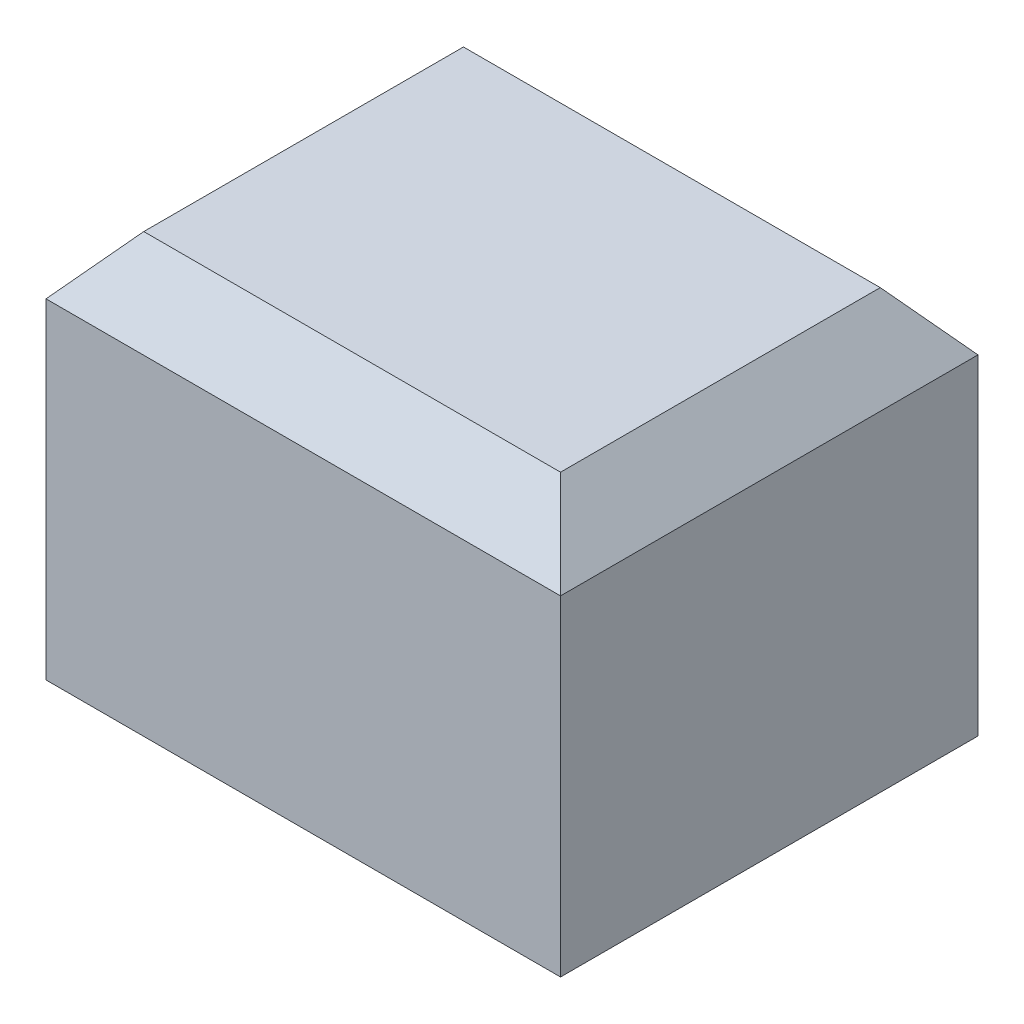
from build123d import *

# Parameters (mm, degrees)
SKETCH1_W                = 5.3
SKETCH1_H                = 4.3
SKETCH1_W_2              = 3.1
SKETCH1_H_2              = 2.1
BODY_EXTRUDE_DEPTH       = 2.8
SKETCH2_W                = 5.3
SKETCH2_H                = 4.3
CAP_EXTRUDE_DEPTH        = 1.2
BED_CHAMFER_SIZE         = 0.6
BED_CHAMFER_SIZE2        = 0.503459779
BED_CHAMFER_PART_2_SIZE  = 0.6
BED_CHAMFER_PART_2_SIZE2 = 0.503459779
BED_CHAMFER_PART_3_SIZE  = 0.6
BED_CHAMFER_PART_3_SIZE2 = 0.503459779
BED_CHAMFER_PART_4_SIZE  = 0.6
BED_CHAMFER_PART_4_SIZE2 = 0.503459779


with BuildPart() as part:
    # Sketch1 → Body Extrude (new body)
    with BuildSketch(Plane(origin=(0, 0, 0), x_dir=(1, 0, 0), z_dir=(0, 1, 0))):
        Rectangle(SKETCH1_W, SKETCH1_H)
        Rectangle(SKETCH1_W_2, SKETCH1_H_2, mode=Mode.SUBTRACT)
    extrude(amount=BODY_EXTRUDE_DEPTH)

    # Sketch2 → Cap Extrude (add)
    with BuildSketch(Plane(origin=(0, 2.8, 0), x_dir=(1, 0, 0), z_dir=(0, 1, 0))):
        Rectangle(SKETCH2_W, SKETCH2_H)
    extrude(amount=CAP_EXTRUDE_DEPTH)

    # Bed Chamfer
    bed_chamfer_edges = [part.edges().sort_by_distance(p)[0] for p in [
        (-2.65, 4, 0),
    ]]
    bed_chamfer_side = [part.faces().sort_by_distance(p)[0] for p in [
        (-2.65, 2, 0),
    ]]
    chamfer(bed_chamfer_edges, length=BED_CHAMFER_SIZE, length2=BED_CHAMFER_SIZE2, reference=bed_chamfer_side[0])

    # Bed Chamfer part 2
    bed_chamfer_part_2_edges = [part.edges().sort_by_distance(p)[0] for p in [
        (0, 4, 2.15),
    ]]
    bed_chamfer_part_2_side = [part.faces().sort_by_distance(p)[0] for p in [
        (0, 2, 2.15),
    ]]
    chamfer(bed_chamfer_part_2_edges, length=BED_CHAMFER_PART_2_SIZE, length2=BED_CHAMFER_PART_2_SIZE2, reference=bed_chamfer_part_2_side[0])

    # Bed Chamfer part 3
    bed_chamfer_part_3_edges = [part.edges().sort_by_distance(p)[0] for p in [
        (2.65, 4, 0),
    ]]
    bed_chamfer_part_3_side = [part.faces().sort_by_distance(p)[0] for p in [
        (2.65, 2, 0),
    ]]
    chamfer(bed_chamfer_part_3_edges, length=BED_CHAMFER_PART_3_SIZE, length2=BED_CHAMFER_PART_3_SIZE2, reference=bed_chamfer_part_3_side[0])

    # Bed Chamfer part 4
    bed_chamfer_part_4_edges = [part.edges().sort_by_distance(p)[0] for p in [
        (0, 4, -2.15),
    ]]
    bed_chamfer_part_4_side = [part.faces().sort_by_distance(p)[0] for p in [
        (0, 2, -2.15),
    ]]
    chamfer(bed_chamfer_part_4_edges, length=BED_CHAMFER_PART_4_SIZE, length2=BED_CHAMFER_PART_4_SIZE2, reference=bed_chamfer_part_4_side[0])


solid = part.part
